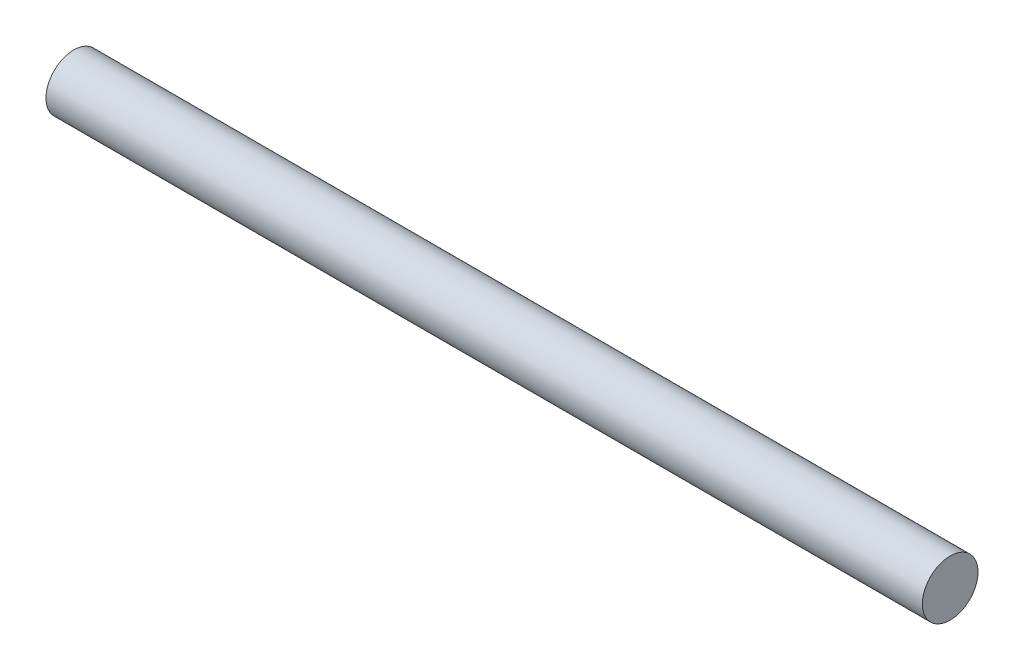
from build123d import *

# Parameters (mm, degrees)
CROQUIS1_R              = 12.7
SALIENTE_EXTRUIR1_DEPTH = 400
CROQUIS2_R              = 4.7625
CORTAR_EXTRUIR1_DEPTH   = 30


with BuildPart() as part:
    # Croquis1 → Saliente-Extruir1 (new body)
    with BuildSketch(Plane(origin=(0, 0, 0), x_dir=(0, 0, -1), z_dir=(1, 0, 0))):
        Circle(CROQUIS1_R)
    extrude(amount=SALIENTE_EXTRUIR1_DEPTH)

    # Croquis2 → Cortar-Extruir1 (cut)
    with BuildSketch(Plane.ZY):
        Circle(CROQUIS2_R)
    extrude(amount=-CORTAR_EXTRUIR1_DEPTH, mode=Mode.SUBTRACT)


solid = part.part
